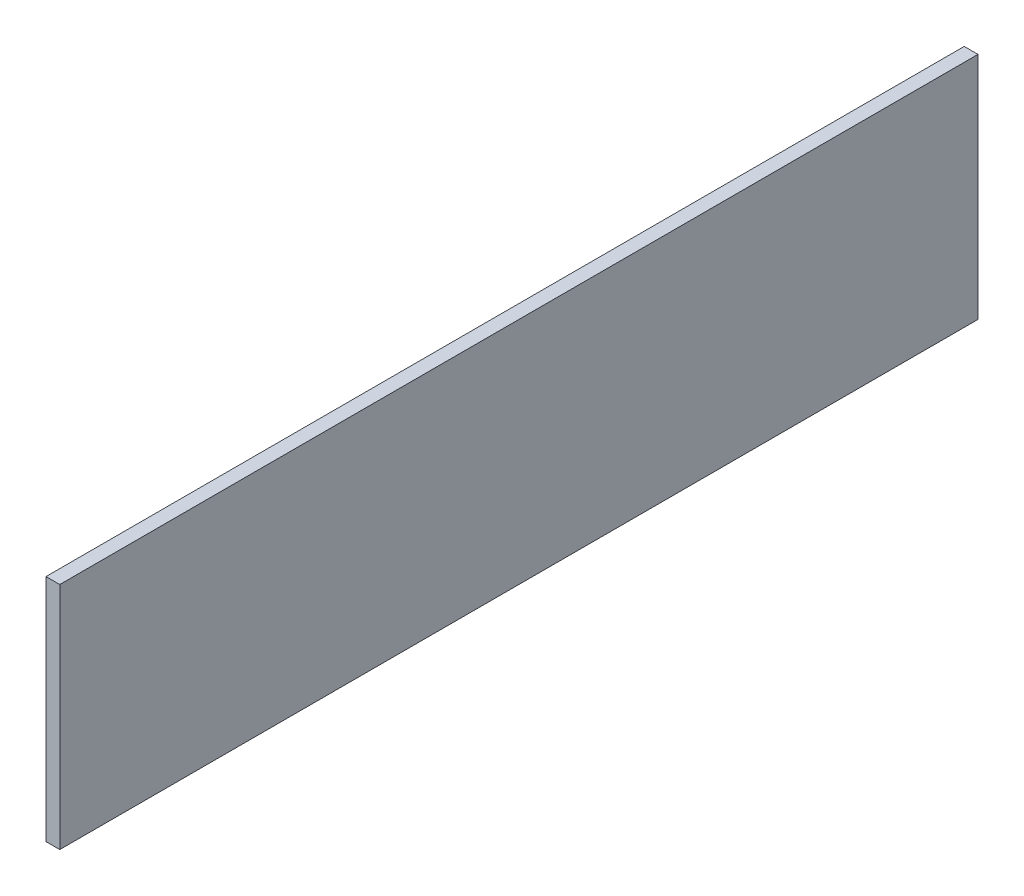
from build123d import *

# Parameters (mm, degrees)
SKETCH1_W           = 200
SKETCH1_H           = 50
BOSS_EXTRUDE1_DEPTH = 3


with BuildPart() as part:
    # Sketch1 → Boss-Extrude1 (new body)
    with BuildSketch(Plane(origin=(0, 0, 0), x_dir=(0, 0, -1), z_dir=(1, 0, 0))):
        Rectangle(SKETCH1_W, SKETCH1_H)
    extrude(amount=BOSS_EXTRUDE1_DEPTH)


solid = part.part
